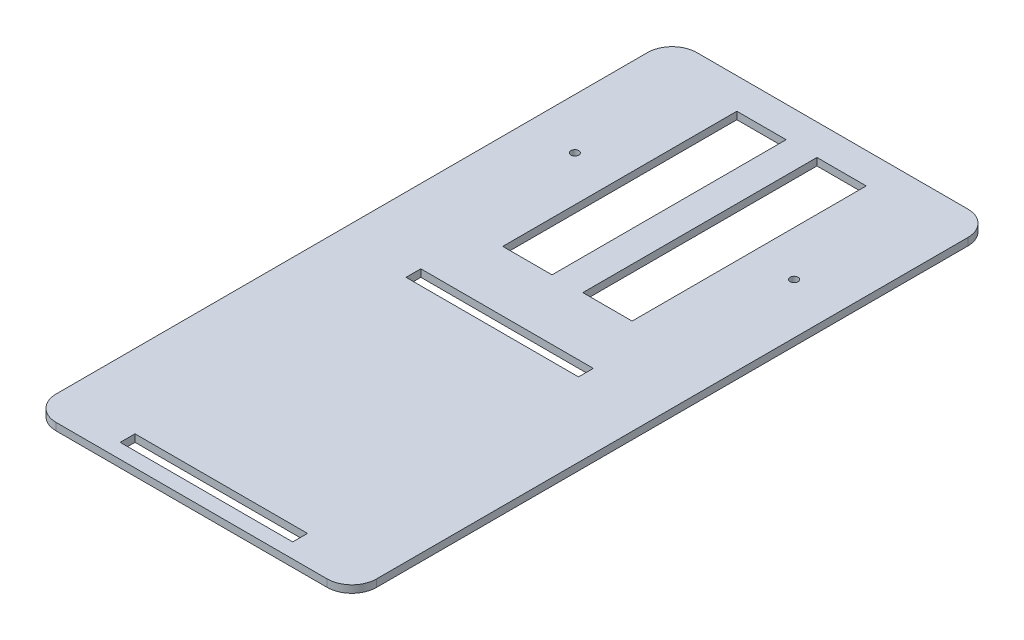
from build123d import *

# Parameters (mm, degrees)
SKETCH1_W               = 130
SKETCH1_H               = 120
BOSS_EXTRUDE1_DEPTH     = 3
CUT_EXTRUDE1_START      = -4
SKETCH2_W               = 20
SKETCH2_H               = 95
CUT_EXTRUDE1_DEPTH      = 5
CUT_EXTRUDE2_START      = -4
SKETCH3_R               = 1.6
CUT_EXTRUDE2_DEPTH      = 5
SKETCH4_W               = 130
SKETCH4_H               = 3
BOSS_EXTRUDE2_DEPTH     = 140
SKETCH5_W               = 70
SKETCH5_H               = 6
CUT_EXTRUDE3_DEPTH      = 1
CUT_EXTRUDE3_DEPTH_BACK = 4
FILLET1_R               = 10


with BuildPart() as part:
    # Sketch1 → Boss-Extrude1 (new body)
    with BuildSketch(Plane(origin=(0, 0, 0), x_dir=(1, 0, 0), z_dir=(0, 1, 0))):
        Rectangle(SKETCH1_W, SKETCH1_H)
    extrude(amount=BOSS_EXTRUDE1_DEPTH)

    # Sketch2 → Cut-Extrude1 (cut)
    with BuildSketch(Plane(origin=(0, 3, 0), x_dir=(1, 0, 0), z_dir=(0, 1, 0)).offset(CUT_EXTRUDE1_START)):
        with Locations((-16.25, 0)):
            Rectangle(SKETCH2_W, SKETCH2_H)
    cut_extrude1 = extrude(amount=CUT_EXTRUDE1_DEPTH, mode=Mode.SUBTRACT)

    # Mirror1: Cut-Extrude1 across plane
    add(cut_extrude1.mirror(Plane(origin=(0, 0, 0), x_dir=(0, 0, 1), z_dir=(1, 0, 0))), mode=Mode.SUBTRACT)

    # Sketch3 → Cut-Extrude2 (cut)
    with BuildSketch(Plane(origin=(0, 3, 0), x_dir=(1, 0, 0), z_dir=(0, 1, 0)).offset(CUT_EXTRUDE2_START)):
        with Locations((44.5, 0)):
            Circle(SKETCH3_R)
    cut_extrude2 = extrude(amount=CUT_EXTRUDE2_DEPTH, mode=Mode.SUBTRACT)

    # Mirror2: Cut-Extrude2 across plane
    add(cut_extrude2.mirror(Plane(origin=(0, 0, 0), x_dir=(0, 0, 1), z_dir=(1, 0, 0))), mode=Mode.SUBTRACT)

    # Sketch4 → Boss-Extrude2 (add)
    with BuildSketch(Plane.XY.offset(60)):
        with Locations((0, 1.5)):
            Rectangle(SKETCH4_W, SKETCH4_H)
    extrude(amount=BOSS_EXTRUDE2_DEPTH)

    # Sketch5 → Cut-Extrude3 (cut, two sides)
    with BuildSketch(Plane(origin=(0, 3, 0), x_dir=(1, 0, 0), z_dir=(0, 1, 0))) as cut_extrude3_sk:
        with Locations((0, -75)):
            Rectangle(SKETCH5_W, SKETCH5_H)
        with Locations((0, -191)):
            Rectangle(SKETCH5_W, SKETCH5_H)
    extrude(amount=CUT_EXTRUDE3_DEPTH, mode=Mode.SUBTRACT)
    extrude(cut_extrude3_sk.sketch, amount=-CUT_EXTRUDE3_DEPTH_BACK, mode=Mode.SUBTRACT)

    # Fillet1
    fillet1_edges = [part.edges().sort_by_distance(p)[0] for p in [
        (-65, 1.5, 200),
        (65, 1.5, 200),
        (-65, 1.5, -60),
        (65, 1.5, -60),
    ]]
    fillet(fillet1_edges, radius=FILLET1_R)


solid = part.part
